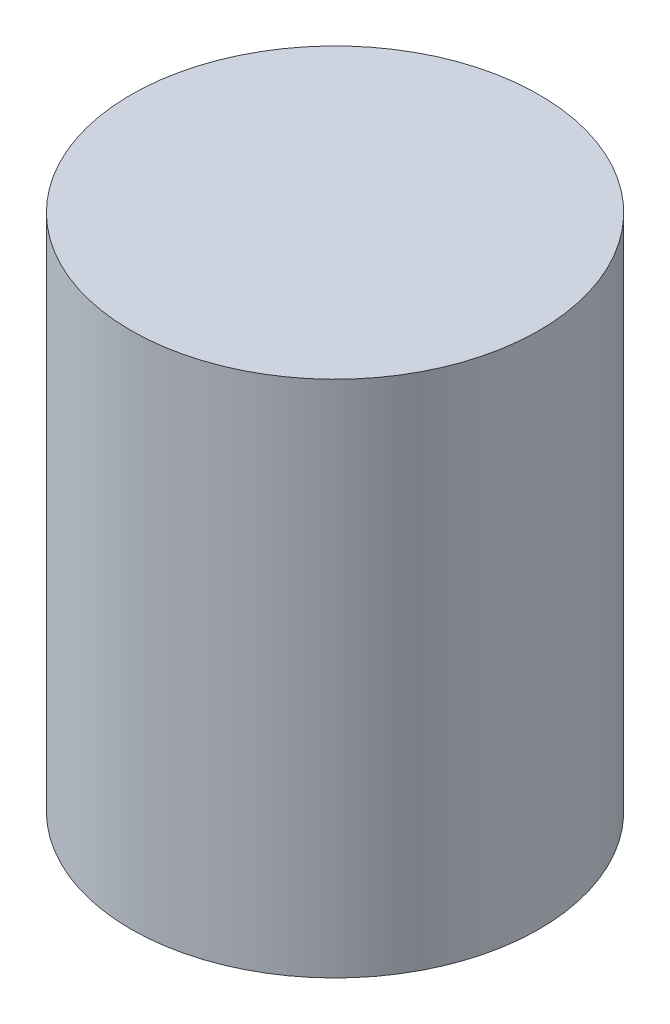
from build123d import *

# Parameters (mm, degrees)
SKETCH1_R           = 11
BOSS_EXTRUDE1_DEPTH = 27.94
SKETCH2_R           = 10.4267
CUT_EXTRUDE1_DEPTH  = 1.1684
SKETCH3_R           = 11
BOSS_EXTRUDE2_DEPTH = 20.32


with BuildPart() as part:
    # Sketch1 → Boss-Extrude1 (new body)
    with BuildSketch(Plane(origin=(0, 0, 0), x_dir=(1, 0, 0), z_dir=(0, 1, 0))):
        Circle(SKETCH1_R)
    extrude(amount=BOSS_EXTRUDE1_DEPTH)

    # Sketch2 → Cut-Extrude1 (cut)
    with BuildSketch(Plane(origin=(0, 12.954, 0), x_dir=(1, 0, 0), z_dir=(0, 1, 0))):
        with BuildLine():
            Line((-17.239436612, 14.563425366), (-16.28375247, -14.840830381))
            Line((-16.28375247, -14.840830381), (21.406068048, -16.295664576))
            Line((21.406068048, -16.295664576), (22.094276354, 14.197317514))
            Line((22.094276354, 14.197317514), (19.887741586, 14.563425366))
            ThreePointArc((19.887741586, 14.563425366), (1.324152487, 14.86501853), (-17.239436612, 14.563425366))
        make_face()
        Circle(SKETCH2_R, mode=Mode.SUBTRACT)
    extrude(amount=-CUT_EXTRUDE1_DEPTH, mode=Mode.SUBTRACT)

    # Sketch3 → Boss-Extrude2 (add)
    with BuildSketch(Plane.XZ):
        Circle(SKETCH3_R)
    extrude(amount=-BOSS_EXTRUDE2_DEPTH)


solid = part.part
